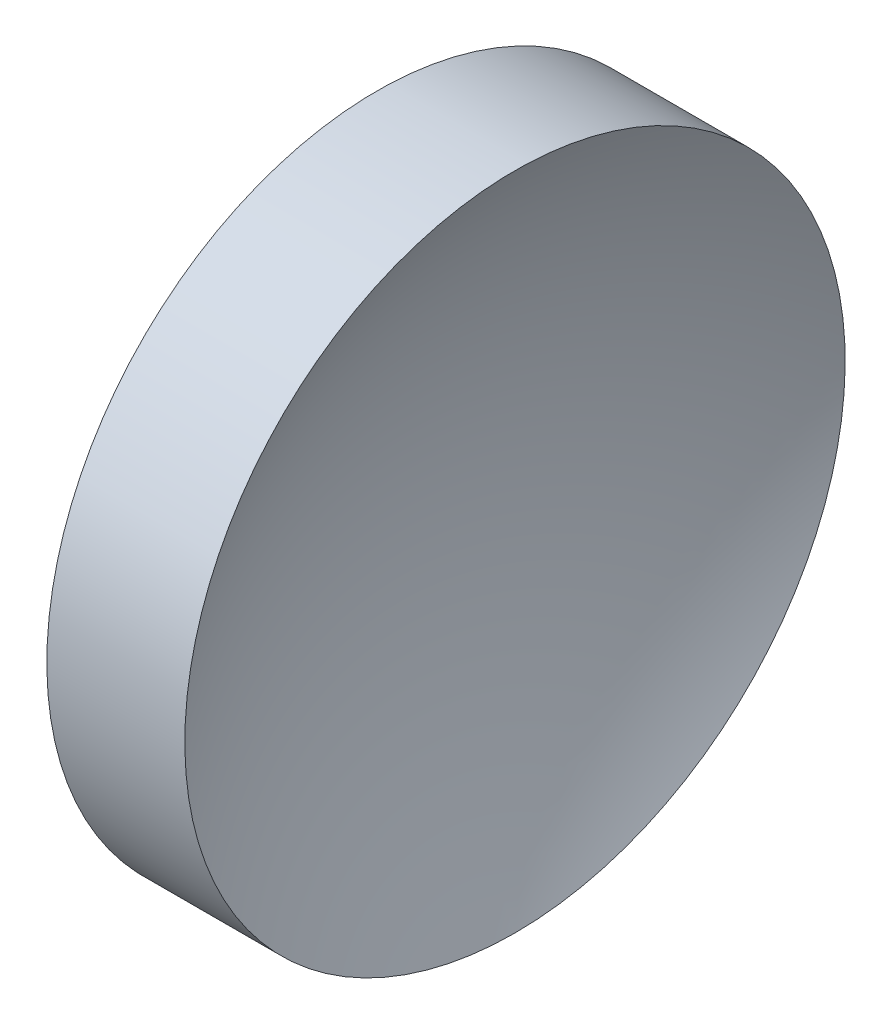
from build123d import *


with BuildPart() as part:
    # 草图1 → 旋转1 (revolve)
    with BuildSketch(Plane.XY, mode=Mode.PRIVATE) as revolve_1_sk:
        with BuildLine():
            Line((57.358190158, 32.578725913), (57.358190158, 45.078725913))
            Line((57.358190158, 45.078725913), (62.582832989, 45.078725913))
            ThreePointArc((62.582832989, 45.078725913), (60.17734066, 39.033341345), (59.358190158, 32.578725913))
            Line((59.358190158, 32.578725913), (57.358190158, 32.578725913))
        make_face()
    revolve(revolve_1_sk.sketch.rotate(Axis((55.007394624, 32.578725913, 0), (1, 0, 0)), 180), axis=Axis((55.007394624, 32.578725913, 0), (1, 0, 0)))  # turned: the seam where the file's is


solid = part.part
